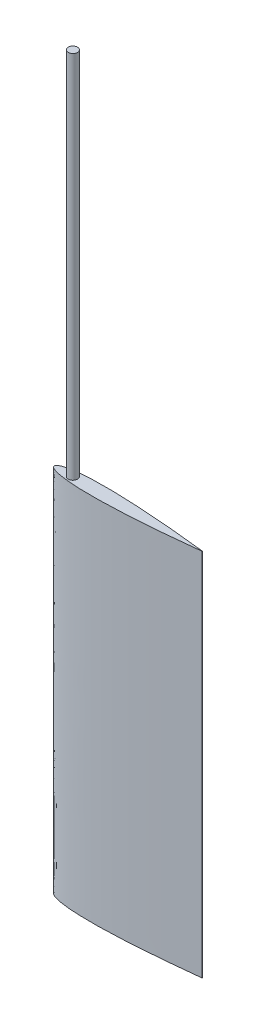
from build123d import *

# Parameters (mm, degrees)
BOSS_EXTRUDE1_DEPTH = 127
SKETCH2_R           = 1.5875
BOSS_EXTRUDE2_DEPTH = 127


with BuildPart() as part:
    # Sketch1 → Boss-Extrude1 (new body)
    with BuildSketch(Plane(origin=(0, 0, 0), x_dir=(1, 0, 0), z_dir=(0, 1, 0))):
        with BuildLine():
            Line((50.8, 0.0508), (50.8, 0))
            Line((50.8, 0), (0, 0))
            add(Edge.make_bspline(
                [(0, 0), (2.1206e-05, 0.039862356), (0.00576139, 0.100210815), (0.02588624, 0.181796342), (0.069775891, 0.280176128), (0.120575217, 0.364149982), (0.192542699, 0.456567036), (0.297995582, 0.56395117), (0.461517576, 0.696025526), (0.729954447, 0.86620071), (1.189974544, 1.089344132), (2.014085288, 1.384232868), (3.467702723, 1.745899213), (5.80495673, 2.119084939), (8.932898979, 2.399213465), (12.655774362, 2.545037355), (16.683138242, 2.554936035), (20.707251866, 2.460374136), (24.73165904, 2.287560046), (28.245559772, 2.084773383), (31.263100941, 1.880463108), (33.764674844, 1.694323754), (35.785394098, 1.533417253), (38.264864841, 1.326235245), (40.822648215, 1.095076006), (43.245178187, 0.865215439), (45.86576662, 0.596961966), (47.668485926, 0.40718912), (49.440869506, 0.208017066), (50.345324939, 0.104031083), (50.8, 0.0508)],
                knots=[0, 0, 0, 0, 0, 0.00279759, 0.004281117, 0.005885353, 0.007583672, 0.009710733, 0.012532865, 0.016488419, 0.02239172, 0.032104263, 0.048557293, 0.078181021, 0.127993702, 0.199052552, 0.270111406, 0.341170261, 0.412229116, 0.483287971, 0.554346827, 0.589876255, 0.625405682, 0.66093511, 0.696464538, 0.767523393, 0.803052821, 0.838582249, 0.874111677, 0.909641105, 0.909641105, 0.909641105, 0.909641105, 0.909641105], degree=4))
        make_face()
    extrude(amount=BOSS_EXTRUDE1_DEPTH)

    # Mirror1: part across plane


with BuildPart() as part_1:
    add(part.part)
    add(part.part.mirror(Plane(origin=(50.8, 127, 0), x_dir=(1, 0, 0), z_dir=(0, 0, -1))))

    # Sketch2 → Boss-Extrude2 (add)
    with BuildSketch(Plane(origin=(0, 127, 0), x_dir=(1, 0, 0), z_dir=(0, 1, 0))):
        with Locations((6.35, 0)):
            Circle(SKETCH2_R)
    extrude(amount=BOSS_EXTRUDE2_DEPTH)


solid = part_1.part
